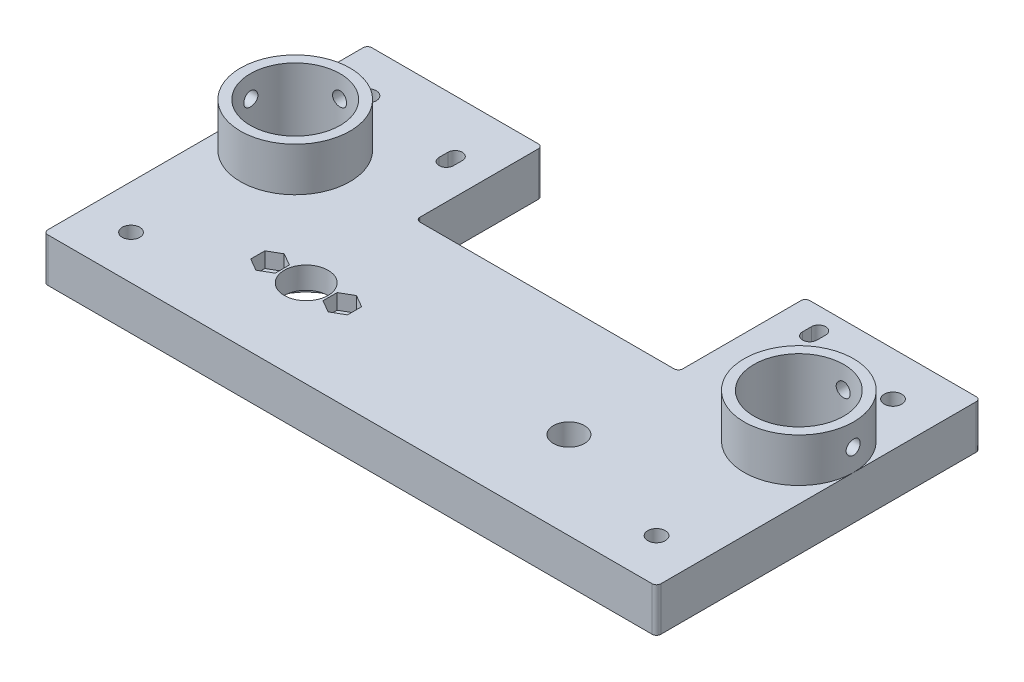
from build123d import *

# Parameters (mm, degrees)
SALIENTE_EXTRUIR1_DEPTH = 10
CROQUIS3_R              = 5
CROQUIS3_R_2            = 3.55
CROQUIS3_R_3            = 1.6
CORTAR_EXTRUIR1_DEPTH   = 11
CORTAR_EXTRUIR2_DEPTH   = 3.5
CROQUIS5_R              = 11.55
CORTAR_EXTRUIR3_DEPTH   = 5
CROQUIS8_W              = 15
CROQUIS8_H              = 29
SALIENTE_EXTRUIR2_DEPTH = 10
CROQUIS9_W              = 25
CROQUIS9_H              = 25
SALIENTE_EXTRUIR4_DEPTH = 10
CROQUIS13_R             = 12.5
SALIENTE_EXTRUIR5_DEPTH = 10
CROQUIS15_R             = 10.25
CORTAR_EXTRUIR5_DEPTH   = 20
CROQUIS16_R             = 1.6
CORTAR_EXTRUIR6_DEPTH   = 10
CROQUIS17_W             = 25
CROQUIS17_H             = 16.5
CROQUIS17_R             = 2
CROQUIS17_H_2           = 32.5
SALIENTE_EXTRUIR6_DEPTH = 10
REDONDEO1_R             = 1
CROQUIS18_W             = 5.6
CROQUIS18_H             = 12
CORTAR_EXTRUIR7_DEPTH   = 3
CORTAR_EXTRUIR10_START  = 60
CROQUIS19_R             = 1.6
CORTAR_EXTRUIR10_DEPTH  = 11.0000001


with BuildPart() as part:
    # Croquis1 → Saliente-Extruir1 (new body)
    with BuildSketch(Plane(origin=(0, 0, 0), x_dir=(1, 0, 0), z_dir=(0, 1, 0))):
        Polygon((-45, -22.5), (45, -22.5), (45, 22.5), (0, 22.5), (-45, 22.5), align=None)
    extrude(amount=SALIENTE_EXTRUIR1_DEPTH)

    # Croquis3 → Cortar-Extruir1 (cut, through all)
    with BuildSketch(Plane(origin=(0, 10, 0), x_dir=(1, 0, 0), z_dir=(0, 1, 0))):
        with Locations((-30, -2.5)):
            Circle(CROQUIS3_R)
        with Locations((30, -2.5)):
            Circle(CROQUIS3_R_2)
        with Locations((-38.25, -2.5)):
            Circle(CROQUIS3_R_3)
        with Locations((-21.75, -2.5)):
            Circle(CROQUIS3_R_3)
    extrude(amount=-CORTAR_EXTRUIR1_DEPTH, mode=Mode.SUBTRACT)

    # Croquis4 → Cortar-Extruir2 (cut)
    with BuildSketch(Plane(origin=(0, 10, 0), x_dir=(1, 0, 0), z_dir=(0, 1, 0))):
        Polygon((-38.25, 0.733161507), (-41.05, -0.883419246), (-41.05, -4.116580754), (-38.25, -5.733161507), (-35.45, -4.116580754), (-35.45, -0.883419246), align=None)
        Polygon((-21.75, 0.733161507), (-24.55, -0.883419246), (-24.55, -4.116580754), (-21.75, -5.733161507), (-18.95, -4.116580754), (-18.95, -0.883419246), align=None)
    extrude(amount=-CORTAR_EXTRUIR2_DEPTH, mode=Mode.SUBTRACT)

    # Croquis5 → Cortar-Extruir3 (cut)
    with BuildSketch(Plane.XZ):
        with Locations((-30, 2.5)):
            Circle(CROQUIS5_R)
    extrude(amount=-CORTAR_EXTRUIR3_DEPTH, mode=Mode.SUBTRACT)

    # Croquis8 → Saliente-Extruir2 (add)
    with BuildSketch(Plane(origin=(0, 10, 0), x_dir=(1, 0, 0), z_dir=(0, 1, 0))):
        with Locations((-37.5, 37)):
            Rectangle(CROQUIS8_W, CROQUIS8_H)
        with BuildLine():
            Line((-36.35, 39.5), (-36.35, 37.5))
            ThreePointArc((-36.35, 37.5), (-38, 35.85), (-39.65, 37.5))
            Line((-39.65, 37.5), (-39.65, 39.5))
            ThreePointArc((-39.65, 39.5), (-38, 41.15), (-36.35, 39.5))
        make_face(mode=Mode.SUBTRACT)
        with Locations((37.5, 37)):
            Rectangle(CROQUIS8_W, CROQUIS8_H)
        with BuildLine():
            Line((39.65, 46.5), (39.65, 44.5))
            ThreePointArc((39.65, 44.5), (38, 42.85), (36.35, 44.5))
            Line((36.35, 44.5), (36.35, 46.5))
            ThreePointArc((36.35, 46.5), (38, 48.15), (39.65, 46.5))
        make_face(mode=Mode.SUBTRACT)
    extrude(amount=-SALIENTE_EXTRUIR2_DEPTH)

    # Croquis9 → Saliente-Extruir4 (add)
    with BuildSketch(Plane(origin=(0, 0, 0), x_dir=(1, 0, 0), z_dir=(0, 1, 0))):
        with Locations((-57.5, 22.5)):
            Rectangle(CROQUIS9_W, CROQUIS9_H)
        with Locations((57.5, 22.5)):
            Rectangle(CROQUIS9_W, CROQUIS9_H)
    extrude(amount=SALIENTE_EXTRUIR4_DEPTH)

    # Croquis13 → Saliente-Extruir5 (add)
    with BuildSketch(Plane(origin=(0, 10, 0), x_dir=(1, 0, 0), z_dir=(0, 1, 0))):
        with Locations((-57.5, 22.5)):
            Circle(CROQUIS13_R)
        with Locations((57.5, 22.5)):
            Circle(CROQUIS13_R)
    extrude(amount=SALIENTE_EXTRUIR5_DEPTH)

    # Croquis15 → Cortar-Extruir5 (cut)
    with BuildSketch(Plane(origin=(0, 20, 0), x_dir=(1, 0, 0), z_dir=(0, 1, 0))):
        with Locations((-57.5, 22.5)):
            Circle(CROQUIS15_R)
        with Locations((57.5, 22.5)):
            Circle(CROQUIS15_R)
    extrude(amount=-CORTAR_EXTRUIR5_DEPTH, mode=Mode.SUBTRACT)

    # Croquis16 → Cortar-Extruir6 (cut)
    with BuildSketch(Plane(origin=(0, 0, -35), x_dir=(-1, 0, 0), z_dir=(0, 0, -1))):
        with Locations((-57.5, 15)):
            Circle(CROQUIS16_R)
        with Locations((57.5, 15)):
            Circle(CROQUIS16_R)
    extrude(amount=-CORTAR_EXTRUIR6_DEPTH, mode=Mode.SUBTRACT)

    # Croquis17 → Saliente-Extruir6 (add)
    with BuildSketch(Plane(origin=(0, 0, 0), x_dir=(1, 0, 0), z_dir=(0, 1, 0))):
        with Locations((57.5, 43.25)):
            Rectangle(CROQUIS17_W, CROQUIS17_H)
        with Locations((60, 41.5)):
            Circle(CROQUIS17_R, mode=Mode.SUBTRACT)
        with Locations((57.5, -6.25)):
            Rectangle(CROQUIS17_W, CROQUIS17_H_2)
        with Locations((60, -12.5)):
            Circle(CROQUIS17_R, mode=Mode.SUBTRACT)
        with Locations((-57.5, 43.25)):
            Rectangle(CROQUIS17_W, CROQUIS17_H)
        with Locations((-60, 41.5)):
            Circle(CROQUIS17_R, mode=Mode.SUBTRACT)
        with Locations((-57.5, -6.25)):
            Rectangle(CROQUIS17_W, CROQUIS17_H_2)
        with Locations((-60, -12.5)):
            Circle(CROQUIS17_R, mode=Mode.SUBTRACT)
    extrude(amount=SALIENTE_EXTRUIR6_DEPTH)

    # Redondeo1
    redondeo1_edges = [part.edges().sort_by_distance(p)[0] for p in [
        (-30, 5, -22.5),
        (-30, 5, -51.5),
        (-70, 5, -51.5),
        (-70, 5, 22.5),
        (70, 5, -51.5),
        (70, 5, 22.5),
        (30, 5, -22.5),
        (30, 5, -51.5),
    ]]
    fillet(redondeo1_edges, radius=REDONDEO1_R)

    # Croquis18 → Cortar-Extruir7 (cut)
    with BuildSketch(Plane.XZ):
        with Locations((-38, -38.5)):
            Rectangle(CROQUIS18_W, CROQUIS18_H)
        with Locations((38, -45.5)):
            Rectangle(CROQUIS18_W, CROQUIS18_H)
    extrude(amount=-CORTAR_EXTRUIR7_DEPTH, mode=Mode.SUBTRACT)

    # Croquis19 → Cortar-Extruir10 (cut, through all)
    with BuildSketch(Plane(origin=(0, 0, 0), x_dir=(0, 0, -1), z_dir=(1, 0, 0)).offset(CORTAR_EXTRUIR10_START)):
        with Locations((22.5, 15)):
            Circle(CROQUIS19_R)
    cortar_extruir10 = extrude(amount=CORTAR_EXTRUIR10_DEPTH, mode=Mode.SUBTRACT)

    # Simetría1: Cortar-Extruir10 across plane
    add(cortar_extruir10.mirror(Plane(origin=(0, 0, 0), x_dir=(0, 0, 1), z_dir=(1, 0, 0))), mode=Mode.SUBTRACT)


solid = part.part
